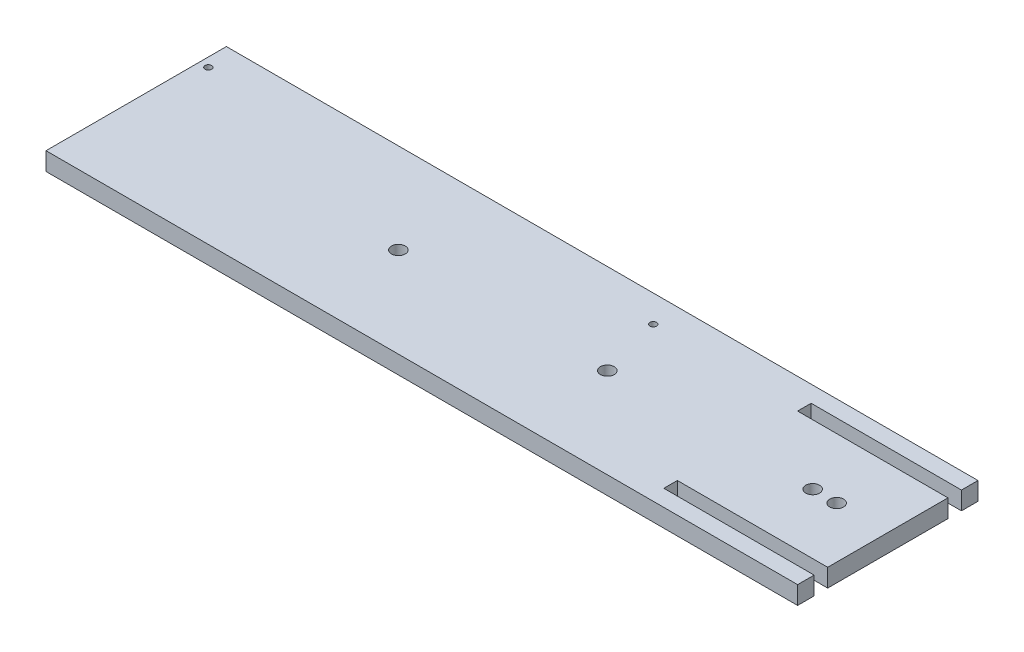
from build123d import *

# Parameters (mm, degrees)
SKETCH1_W           = 250
SKETCH1_H           = 60
SKETCH1_R           = 2.3
BOSS_EXTRUDE1_DEPTH = 6
SKETCH2_W           = 50
SKETCH2_H           = 4.5
CUT_EXTRUDE1_DEPTH  = 6
SKETCH3_R           = 1.1
CUT_EXTRUDE2_DEPTH  = 10


with BuildPart() as part:
    # Sketch1 → Boss-Extrude1 (new body)
    with BuildSketch(Plane(origin=(0, 0, 0), x_dir=(1, 0, 0), z_dir=(0, 1, 0))):
        Rectangle(SKETCH1_W, SKETCH1_H)
        with Locations((108, 0)):
            Circle(SKETCH1_R, mode=Mode.SUBTRACT)
        with Locations((100, 0)):
            Circle(SKETCH1_R, mode=Mode.SUBTRACT)
        with Locations((31.7, 0)):
            Circle(SKETCH1_R, mode=Mode.SUBTRACT)
        with Locations((-37.8, 0)):
            Circle(SKETCH1_R, mode=Mode.SUBTRACT)
    extrude(amount=BOSS_EXTRUDE1_DEPTH)

    # Sketch2 → Cut-Extrude1 (cut)
    with BuildSketch(Plane(origin=(0, 6, 0), x_dir=(1, 0, 0), z_dir=(0, 1, 0))):
        with Locations((100, -22.25)):
            Rectangle(SKETCH2_W, SKETCH2_H)
        with Locations((100, 22.25)):
            Rectangle(SKETCH2_W, SKETCH2_H)
    extrude(amount=-CUT_EXTRUDE1_DEPTH, mode=Mode.SUBTRACT)

    # Sketch3 → Cut-Extrude2 (cut)
    with BuildSketch(Plane.XZ):
        with Locations((-122, -21)):
            Circle(SKETCH3_R)
        with Locations((26, -21)):
            Circle(SKETCH3_R)
    extrude(amount=-CUT_EXTRUDE2_DEPTH, mode=Mode.SUBTRACT)


solid = part.part
